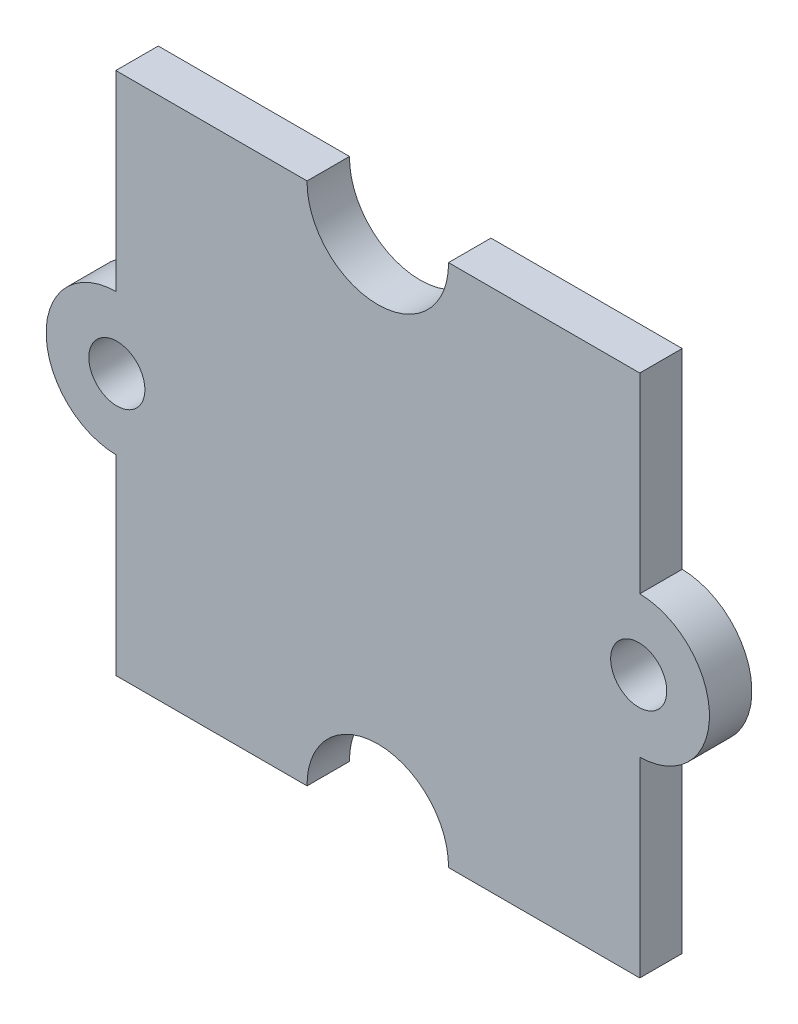
from build123d import *

# Parameters (mm, degrees)
ESQUISSE1_R        = 1.07
BOSS_EXTRU_1_DEPTH = 1.62


with BuildPart() as part:
    # Esquisse1 → Boss.-Extru.1 (new body)
    with BuildSketch(Plane.XY):
        with BuildLine():
            Line((-10, -2.699703687), (-10, -10))
            Line((-10, -10), (-2.699703687, -10))
            ThreePointArc((-2.699703687, -10), (0, -7.26), (2.699703687, -10))
            Line((2.699703687, -10), (10, -10))
            Line((10, -10), (10, -2.699703687))
            ThreePointArc((10, -2.699703687), (12.66, 0), (10, 2.699703687))
            Line((10, 2.699703687), (10, 10))
            Line((10, 10), (2.699703687, 10))
            ThreePointArc((2.699703687, 10), (0, 7.26), (-2.699703687, 10))
            Line((-2.699703687, 10), (-10, 10))
            Line((-10, 10), (-10, 2.699703687))
            ThreePointArc((-10, 2.699703687), (-12.66, 0), (-10, -2.699703687))
        make_face()
        with Locations((-9.96, 0)):
            Circle(ESQUISSE1_R, mode=Mode.SUBTRACT)
        with Locations((9.96, 0)):
            Circle(ESQUISSE1_R, mode=Mode.SUBTRACT)
    extrude(amount=BOSS_EXTRU_1_DEPTH)


solid = part.part
